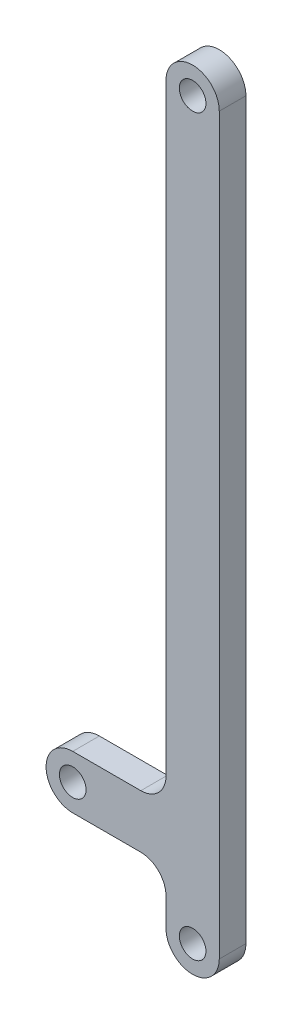
from build123d import *

# Parameters (mm, degrees)
SKETCH1_R           = 6.35
BOSS_EXTRUDE3_DEPTH = 12.7


with BuildPart() as part:
    # Sketch1 → Boss-Extrude3 (new body)
    with BuildSketch(Plane.XY):
        with BuildLine():
            Line((-12.7, -336.612), (-12.7, -350))
            ThreePointArc((-12.7, -350), (0, -362.7), (12.7, -350))
            Line((12.7, -350), (12.7, 0))
            ThreePointArc((12.7, 0), (0, 12.7), (-12.7, 0))
            Line((-12.7, 0), (-12.7, -287.212))
            ThreePointArc((-12.7, -287.212), (-16.214718626, -295.697281374), (-24.7, -299.212))
            Line((-24.7, -299.212), (-57.15, -299.212))
            ThreePointArc((-57.15, -299.212), (-69.85, -311.912), (-57.15, -324.612))
            Line((-57.15, -324.612), (-24.7, -324.612))
            ThreePointArc((-24.7, -324.612), (-16.214718626, -328.126718626), (-12.7, -336.612))
        make_face()
        Circle(SKETCH1_R, mode=Mode.SUBTRACT)
        with Locations((-57.15, -311.912)):
            Circle(SKETCH1_R, mode=Mode.SUBTRACT)
        with Locations((0, -350)):
            Circle(SKETCH1_R, mode=Mode.SUBTRACT)
    extrude(amount=BOSS_EXTRUDE3_DEPTH)


solid = part.part
